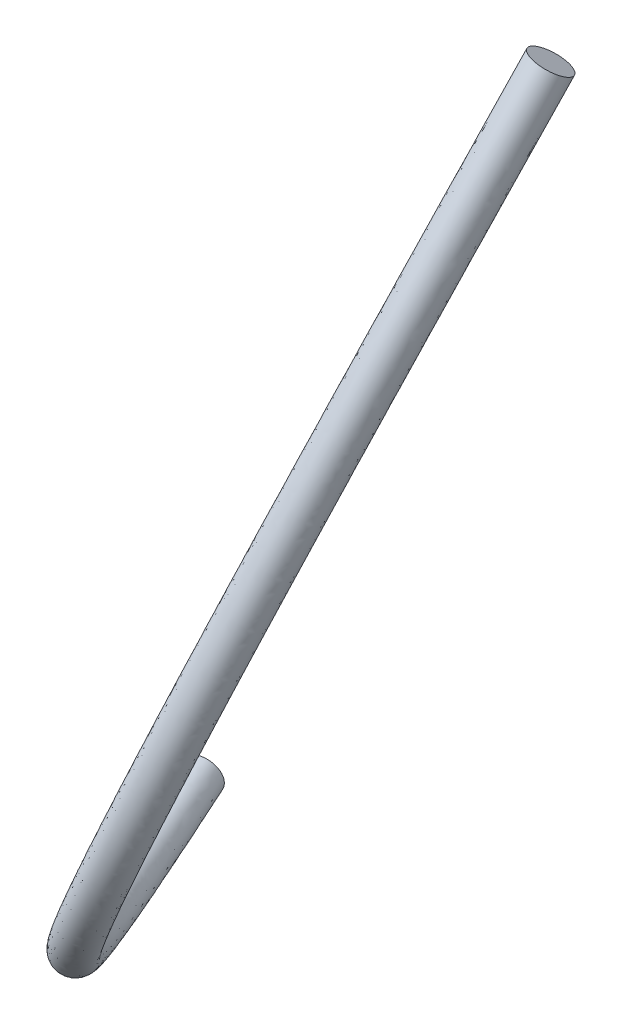
from build123d import *

# Parameters (mm, degrees)
SWEEP_1_PROFILE_R = 3


with BuildPart() as part:
    # 扫描1: sweep along a curve in space
    with BuildLine() as sweep_1_path:
        add(Edge.make_bspline(
            [(0, 0, 0), (31.618290267, -16.490384309, 88.914737371), (64, 132.50247531, 9.562645318)],
            knots=[0, 0, 0, 1, 1, 1], degree=2))
    # 扫描1 profile (on start of the path) → 扫描1 (sweep)
    with BuildSketch(Plane(origin=(0, 0, 0), x_dir=(0.94220077, 0, -0.335048816), z_dir=(0.330047668, -0.172134952, 0.928136894))):
        Circle(SWEEP_1_PROFILE_R)
    sweep(path=sweep_1_path.line)


solid = part.part
